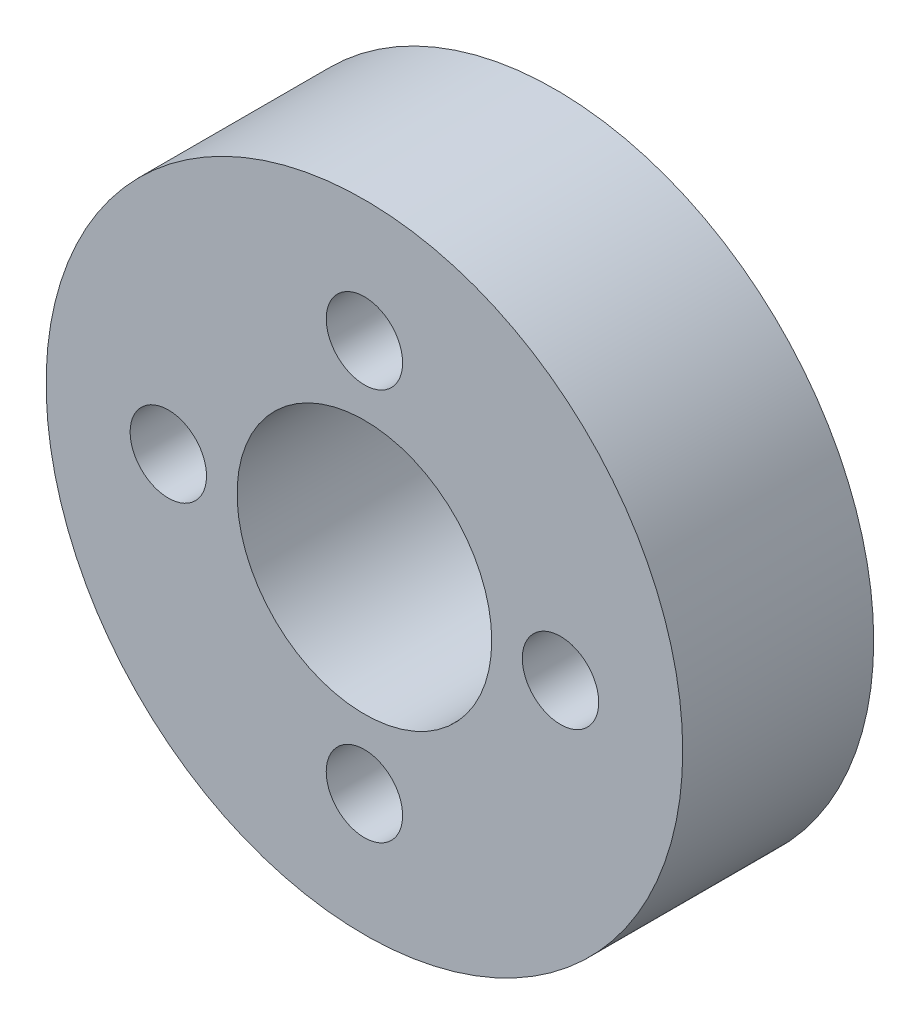
from build123d import *

# Parameters (mm, degrees)
SKETCH1_R           = 15.875
SKETCH1_R_2         = 6.35
BOSS_EXTRUDE1_DEPTH = 9.525
SKETCH2_R           = 1.905
CUT_EXTRUDE1_DEPTH  = 9.525
CIRPATTERN1_COUNT   = 4


with BuildPart() as part:
    # Sketch1 → Boss-Extrude1 (new body)
    with BuildSketch(Plane.XY):
        Circle(SKETCH1_R)
        Circle(SKETCH1_R_2, mode=Mode.SUBTRACT)
    extrude(amount=BOSS_EXTRUDE1_DEPTH)

    # Sketch2 → Cut-Extrude1 (cut)
    with BuildSketch(Plane.XY.offset(9.525)):
        with Locations((0, 9.779)):
            Circle(SKETCH2_R)
    cut_extrude1 = extrude(amount=-CUT_EXTRUDE1_DEPTH, mode=Mode.SUBTRACT)

    # CirPattern1: Cut-Extrude1 ×4 about axis
    cirpattern1_axis = Axis((0, 0, 0), (0, 0, 1))
    for i in range(1, CIRPATTERN1_COUNT):
        add(cut_extrude1.rotate(cirpattern1_axis, i * 360 / CIRPATTERN1_COUNT), mode=Mode.SUBTRACT)


solid = part.part
